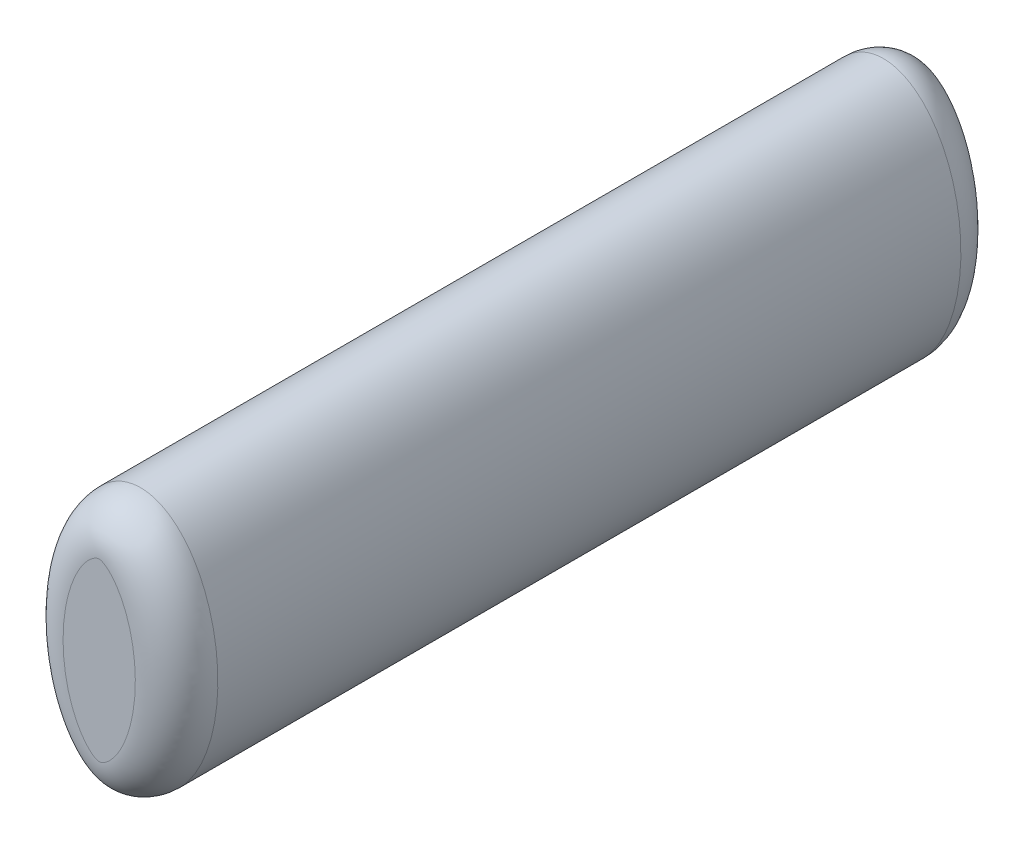
from build123d import *

# Parameters (mm, degrees)
AUFSATZ_LINEAR_AUSTRAGEN2_DEPTH = 80
SKIZZE4_W                       = 40
SKIZZE4_H                       = 5
SCHNITT_LINEAR_AUSTRAGEN1_DEPTH = 1.5
VERRUNDUNG2_R                   = 4


with BuildPart() as part:
    # Skizze1 → Aufsatz-Linear austragen2 (new body)
    with BuildSketch(Plane.XY):
        with BuildLine():
            Line((0, 12.5), (0, 0))
            Line((0, 0), (-7.5, 0))
            add(Edge.make_bspline(
                [(0, 12.5), (-7.5, 12.5), (-7.5, 0)],
                knots=[0, 0, 0, 1.570796327, 1.570796327, 1.570796327], degree=2, weights=[1, 0.707106781, 1]))
        make_face()
    extrude(amount=AUFSATZ_LINEAR_AUSTRAGEN2_DEPTH)

    # Skizze4 → Schnitt-Linear austragen1 (cut)
    with BuildSketch(Plane(origin=(0, 0, 0), x_dir=(0, 0, -1), z_dir=(1, 0, 0))):
        with Locations((-20, 2.5)):
            Rectangle(SKIZZE4_W, SKIZZE4_H)
    extrude(amount=-SCHNITT_LINEAR_AUSTRAGEN1_DEPTH, mode=Mode.SUBTRACT)

    # Verrundung2
    verrundung2_edges = [part.edges().sort_by_distance(p)[0] for p in [
        (-5.885487055, 7.747946344, 80),
        (-5.885487055, 7.747946344, 0),
    ]]
    fillet(verrundung2_edges, radius=VERRUNDUNG2_R)

    # Spiegeln1: part across plane


with BuildPart() as part_1:
    add(part.part)
    add(part.part.mirror(Plane(origin=(0, 0, 80), x_dir=(0, 0, 1), z_dir=(0, 1, 0))))

    # Spiegeln2: part across plane


with BuildPart() as part_2:
    add(part_1.part)
    add(part_1.part.mirror(Plane(origin=(0, 12.5, 80), x_dir=(0, 0, 1), z_dir=(-1, 0, 0))))


solid = part_2.part
